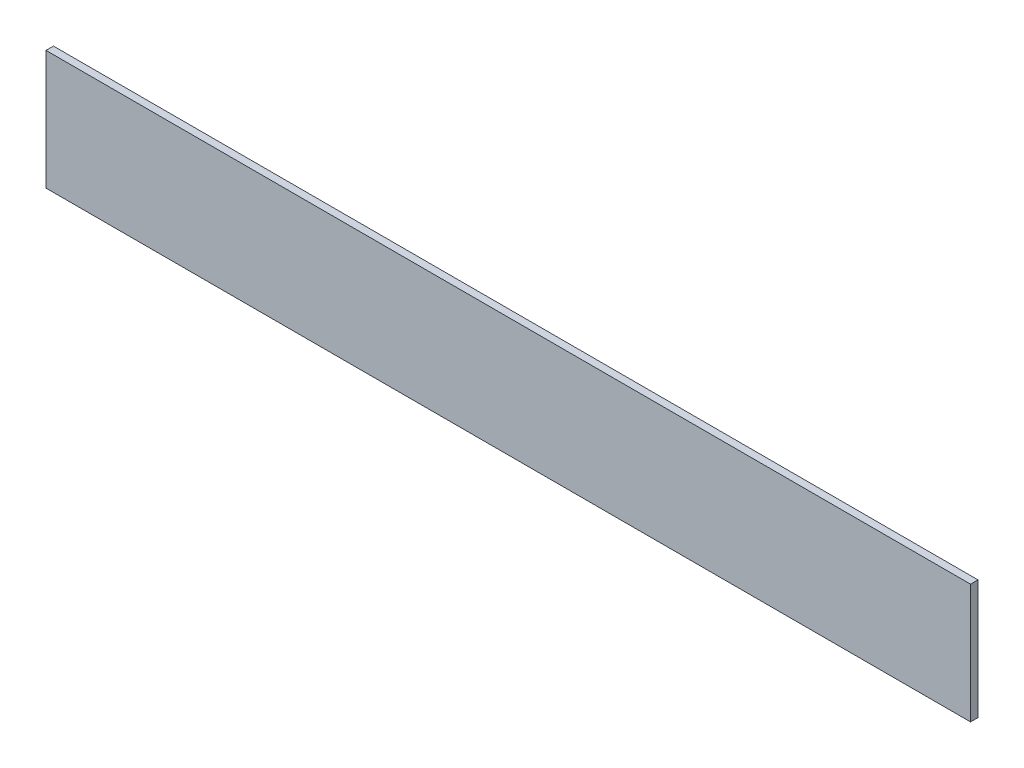
from build123d import *

# Parameters (mm, degrees)
SKETCH1_W           = 393.7
SKETCH1_H           = 50.8
BOSS_EXTRUDE1_DEPTH = 3.175


with BuildPart() as part:
    # Sketch1 → Boss-Extrude1 (new body)
    with BuildSketch(Plane.XY):
        with Locations((196.85, 25.4)):
            Rectangle(SKETCH1_W, SKETCH1_H)
    extrude(amount=BOSS_EXTRUDE1_DEPTH)


solid = part.part
